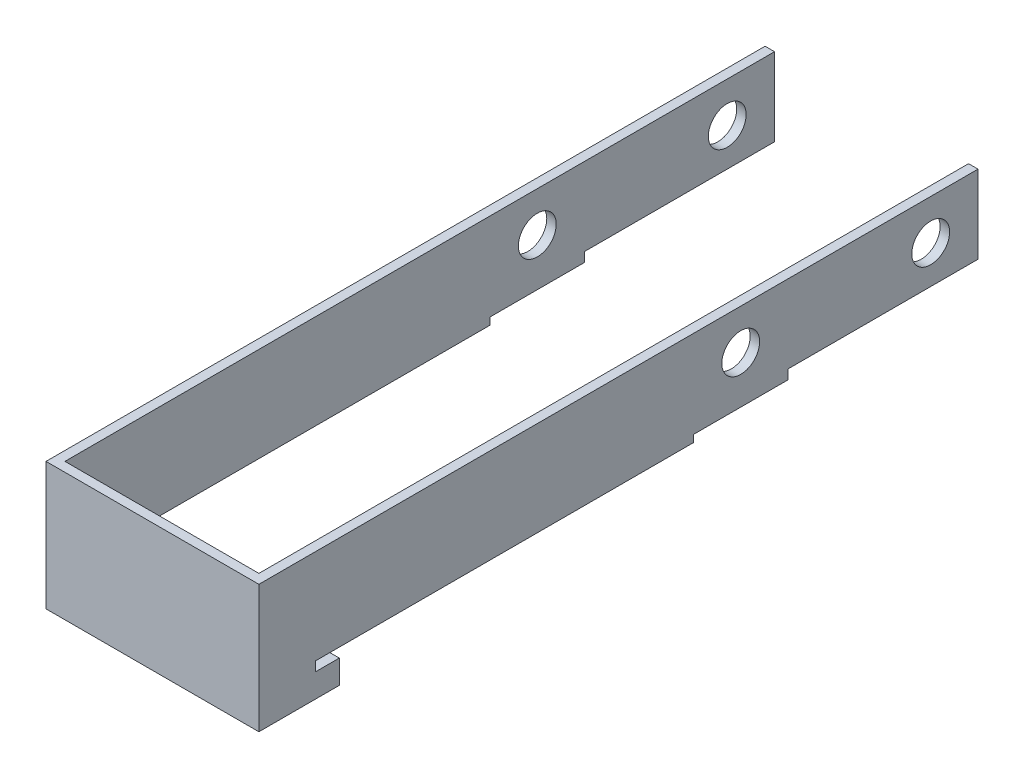
from build123d import *

# Parameters (mm, degrees)
SKETCH1_R           = 4
BOSS_EXTRUDE1_DEPTH = 2
SKETCH2_W           = 45
SKETCH2_H           = 27
BOSS_EXTRUDE2_DEPTH = 2


with BuildPart() as part:
    # Sketch1 → Boss-Extrude1 (new body)
    with BuildSketch(Plane.YZ):
        Polygon((8.5, -10), (8.5, 140), (-18.5, 140), (-18.5, 125), (-13.5, 125), (-13.5, 130), (-11.5, 130), (-11.5, 50.152793502), (-10, 50.152793502), (-10, 30.152793502), (-8, 30.152793502), (-8, -10), align=None)
        Circle(SKETCH1_R, mode=Mode.SUBTRACT)
        with Locations((0, 40.152793502)):
            Circle(SKETCH1_R, mode=Mode.SUBTRACT)
    extrude(amount=-BOSS_EXTRUDE1_DEPTH)


with BuildPart() as body_2:
    # Mirror2: mirrored copy
    add(part.part.mirror(Plane.ZY.offset(22.5)))


with BuildPart() as part_1:
    add(part.part)

    add(body_2.part)  # Boss-Extrude2 merges body 2
    # Sketch2 → Boss-Extrude2 (add)
    with BuildSketch(Plane.XY.offset(140)):
        with Locations((-22.5, -5)):
            Rectangle(SKETCH2_W, SKETCH2_H)
    extrude(amount=BOSS_EXTRUDE2_DEPTH)


solid = part_1.part
